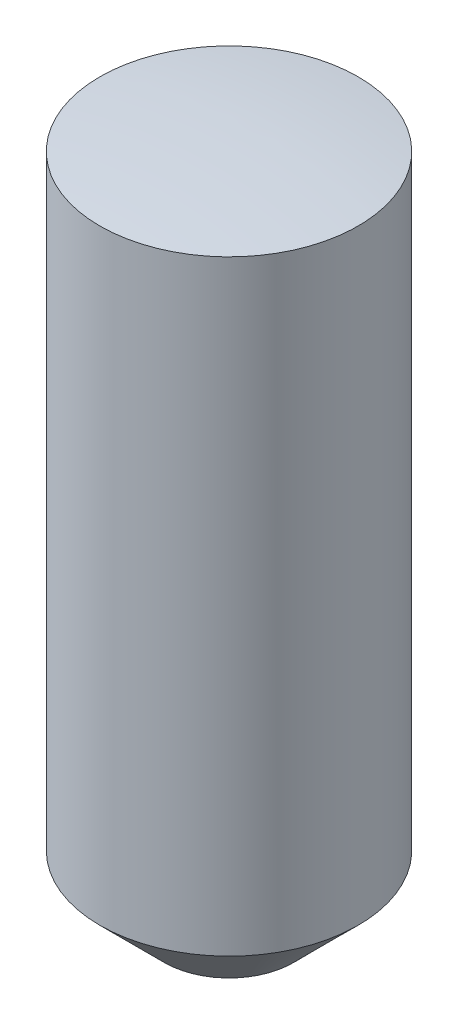
from build123d import *

# Parameters (mm, degrees)
SKETCH1_R                 = 1
BOSS_EXTRUDE_5_25MM_DEPTH = 5.25
F_0_5_X_45_DEG_SIZE       = 0.5


with BuildPart() as part:
    # Sketch1 → Boss-Extrude 5.25mm (new body)
    with BuildSketch(Plane(origin=(0, 0, 0), x_dir=(1, 0, 0), z_dir=(0, 1, 0))):
        Circle(SKETCH1_R)
    extrude(amount=-BOSS_EXTRUDE_5_25MM_DEPTH)

    # 0.5 x 45 deg
    f_0_5_x_45_deg_edges = [part.edges().sort_by_distance(p)[0] for p in [
        (-1, -5.25, 0),
    ]]
    chamfer(f_0_5_x_45_deg_edges, length=F_0_5_X_45_DEG_SIZE)

    # Sketch2 → SR8 (revolve, cut)
    with BuildSketch(Plane.XY):
        with BuildLine():
            Line((0, 2), (-2, 2))
            Line((-2, 2), (-2, -0.254033308))
            ThreePointArc((-2, -0.254033308), (-1.00803434, -0.06376243), (0, 0))
            Line((0, 0), (0, 2))
        make_face()
    revolve(axis=Axis((0, 0, 0), (0, 1, 0)), mode=Mode.SUBTRACT)


solid = part.part
